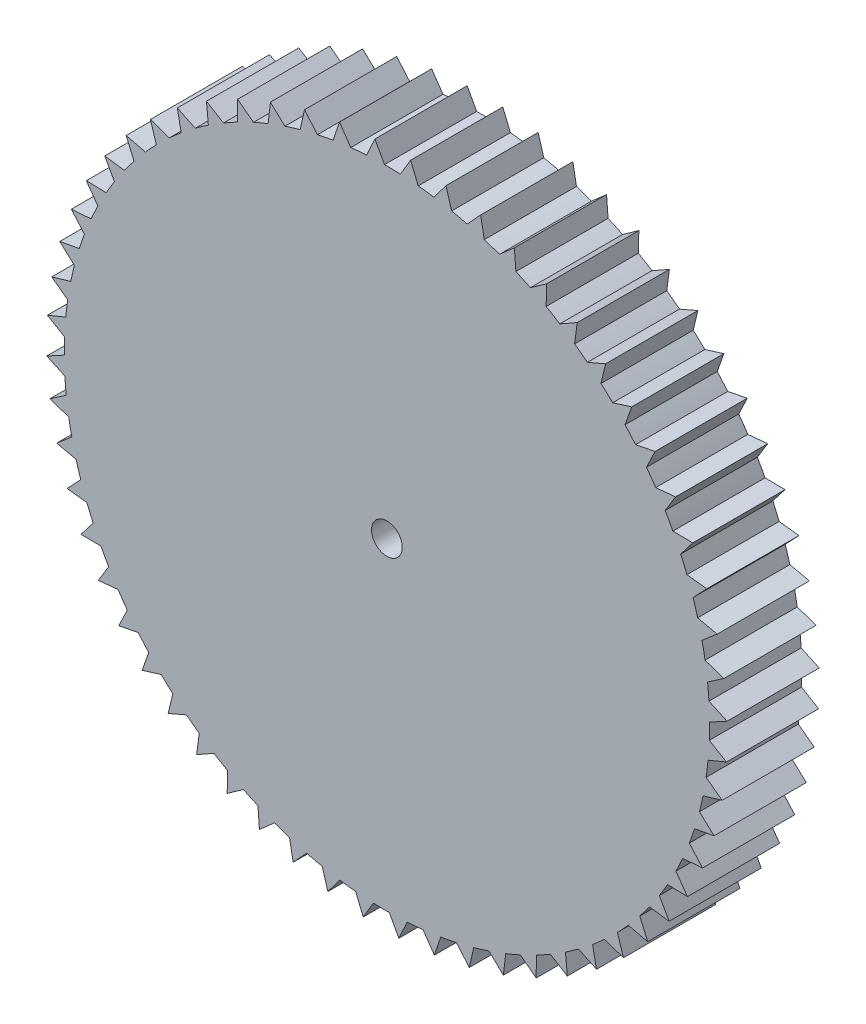
from build123d import *

# Parameters (mm, degrees)
SKETCH3_R           = 10.5
BOSS_EXTRUDE1_DEPTH = 3
SKETCH7_R           = 2
BOSS_EXTRUDE4_DEPTH = 3
BOSS_EXTRUDE5_DEPTH = 3
CIRPATTERN2_COUNT   = 20
SKETCH9_R           = 0.5
CUT_EXTRUDE1_DEPTH  = 6
BOSS_EXTRUDE6_DEPTH = 3
CIRPATTERN3_COUNT   = 60


with BuildPart() as part:
    # Sketch3 → Boss-Extrude1 (new body)
    with BuildSketch(Plane(origin=(0, 0, -25.970633743), x_dir=(-1, 0, 0), z_dir=(0, 0, -1))):
        with Locations((0, 65.2)):
            Circle(SKETCH3_R)
    extrude(amount=BOSS_EXTRUDE1_DEPTH)

    # Sketch7 → Boss-Extrude4 (add)
    with BuildSketch(Plane(origin=(0, 0, -28.970633743), x_dir=(-1, 0, 0), z_dir=(0, 0, -1))):
        with Locations((0, 65.2)):
            Circle(SKETCH7_R)
    extrude(amount=BOSS_EXTRUDE4_DEPTH)

    # Sketch8 → Boss-Extrude5 (add)
    with BuildSketch(Plane(origin=(0, 0, -31.970633743), x_dir=(-1, 0, 0), z_dir=(0, 0, -1))):
        Polygon((0.4, 63.4), (-0.4, 63.4), (0, 62.6), align=None)
    boss_extrude5 = extrude(amount=-BOSS_EXTRUDE5_DEPTH)

    # CirPattern2: Boss-Extrude5 ×20 about axis
    cirpattern2_axis = Axis((0, 65.168195033, 0), (0, 0, 1))
    for i in range(1, CIRPATTERN2_COUNT):
        add(boss_extrude5.rotate(cirpattern2_axis, i * 360 / CIRPATTERN2_COUNT))

    # Sketch9 → Cut-Extrude1 (cut)
    with BuildSketch(Plane(origin=(0, 0, -31.970633743), x_dir=(-1, 0, 0), z_dir=(0, 0, -1))):
        with Locations((0, 65.2)):
            Circle(SKETCH9_R)
    extrude(amount=-CUT_EXTRUDE1_DEPTH, mode=Mode.SUBTRACT)

    # Sketch10 → Boss-Extrude6 (add)
    with BuildSketch(Plane.XY.offset(-25.970633743)):
        Polygon((0.770803644, 76.249147673), (0.427568862, 75.670172212), (1.027914618, 75.628291271), align=None)
    boss_extrude6 = extrude(amount=-BOSS_EXTRUDE6_DEPTH)

    # CirPattern3: Boss-Extrude6 ×60 about axis
    cirpattern3_axis = Axis((0, 65.2, 0), (0, 0, 1))
    for i in range(1, CIRPATTERN3_COUNT):
        add(boss_extrude6.rotate(cirpattern3_axis, i * 360 / CIRPATTERN3_COUNT))


solid = part.part
